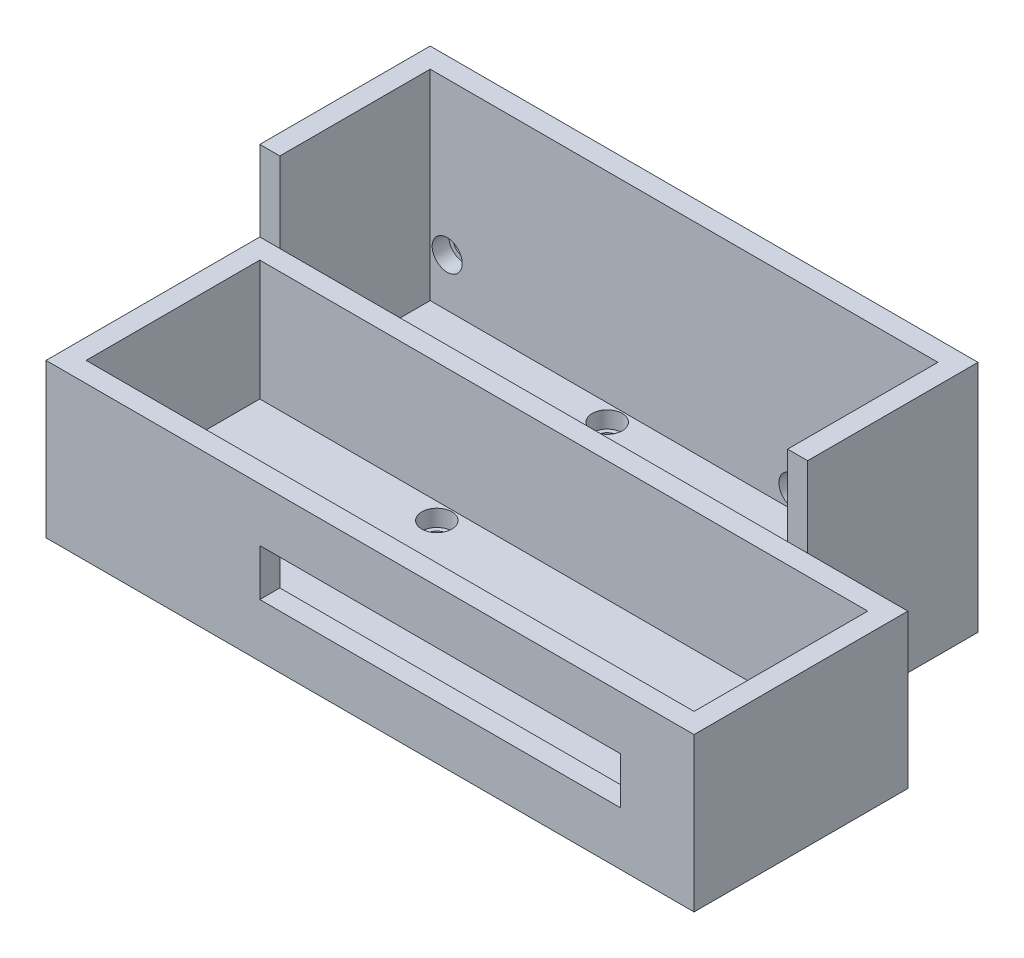
from build123d import *

# Parameters (mm, degrees)
SKETCH1_W           = 91
SKETCH1_H           = 26
BOSS_EXTRUDE1_DEPTH = 5
SKETCH2_R           = 2.25
CUT_EXTRUDE1_DEPTH  = 2.5
SKETCH4_R           = 1.6
CUT_EXTRUDE3_DEPTH  = 3.5
SKETCH5_W           = 97
SKETCH5_H           = 32
SKETCH5_W_2         = 91
SKETCH5_H_2         = 26
BOSS_EXTRUDE2_DEPTH = 23
CUT_EXTRUDE4_REACH  = 34
SKETCH6_W           = 54
SKETCH6_H           = 7
SKETCH9_W           = 76
SKETCH9_H           = 5
BOSS_EXTRUDE3_DEPTH = 22.5
SKETCH10_R          = 2.25
CUT_EXTRUDE5_DEPTH  = 2.5
SKETCH11_R          = 1.6
CUT_EXTRUDE6_DEPTH  = 3.5
BOSS_EXTRUDE4_DEPTH = 35
CUT_EXTRUDE7_REACH  = 84
SKETCH13_R          = 1.6
CUT_EXTRUDE8_REACH  = 59.5
SKETCH14_R          = 1.6
SKETCH16_R          = 2.25
CUT_EXTRUDE10_DEPTH = 2.5
SKETCH17_R          = 2.5
SKETCH17_R_2        = 1.6
BOSS_EXTRUDE5_DEPTH = 1.3
SKETCH18_R          = 2.25
CUT_EXTRUDE11_DEPTH = 1.5


with BuildPart() as part:
    # Sketch1 → Boss-Extrude1 (new body)
    with BuildSketch(Plane(origin=(0, 0, 0), x_dir=(1, 0, 0), z_dir=(0, 1, 0))):
        with Locations((45.5, 13)):
            Rectangle(SKETCH1_W, SKETCH1_H)
    extrude(amount=BOSS_EXTRUDE1_DEPTH)

    # Sketch2 → Cut-Extrude1 (cut)
    with BuildSketch(Plane(origin=(0, 5, 0), x_dir=(1, 0, 0), z_dir=(0, 1, 0))):
        with Locations((2.5, 2.5)):
            Circle(SKETCH2_R)
        with Locations((88.5, 2.5)):
            Circle(SKETCH2_R)
        with Locations((29, 23.5)):
            Circle(SKETCH2_R)
    extrude(amount=-CUT_EXTRUDE1_DEPTH, mode=Mode.SUBTRACT)

    # Sketch4 → Cut-Extrude3 (cut, through all)
    with BuildSketch(Plane(origin=(0, 2.5, 0), x_dir=(1, 0, 0), z_dir=(0, 1, 0))):
        with Locations((2.5, 2.5)):
            Circle(SKETCH4_R)
        with Locations((29, 23.5)):
            Circle(SKETCH4_R)
        with Locations((88.5, 2.5)):
            Circle(SKETCH4_R)
    extrude(amount=-CUT_EXTRUDE3_DEPTH, mode=Mode.SUBTRACT)

    # Sketch5 → Boss-Extrude2 (add)
    with BuildSketch(Plane.XZ):
        with Locations((45.5, -13)):
            Rectangle(SKETCH5_W, SKETCH5_H)
        with Locations((45.5, -13)):
            Rectangle(SKETCH5_W_2, SKETCH5_H_2, mode=Mode.SUBTRACT)
    extrude(amount=-BOSS_EXTRUDE2_DEPTH)

    # Sketch6 → Cut-Extrude4 (cut, up to next)
    with BuildSketch(Plane.XY.offset(3), mode=Mode.PRIVATE) as cut_extrude4_sk1:
        with Locations((56, 11.5)):
            Rectangle(SKETCH6_W, SKETCH6_H)
    cut_extrude4_tool1 = extrude(cut_extrude4_sk1.sketch, amount=-CUT_EXTRUDE4_REACH, mode=Mode.PRIVATE) & part.part
    add(cut_extrude4_tool1.solids().sort_by_distance((56, 11.5, 3))[0], mode=Mode.SUBTRACT)

    # Sketch9 → Boss-Extrude3 (add)
    with BuildSketch(Plane(origin=(0, 0, -29), x_dir=(-1, 0, 0), z_dir=(0, 0, -1))):
        with Locations((-38, 2.5)):
            Rectangle(SKETCH9_W, SKETCH9_H)
    extrude(amount=BOSS_EXTRUDE3_DEPTH)

    # Sketch10 → Cut-Extrude5 (cut)
    with BuildSketch(Plane(origin=(0, 5, 0), x_dir=(1, 0, 0), z_dir=(0, 1, 0))):
        with Locations((29, 49)):
            Circle(SKETCH10_R)
    extrude(amount=-CUT_EXTRUDE5_DEPTH, mode=Mode.SUBTRACT)

    # Sketch11 → Cut-Extrude6 (cut, through all)
    with BuildSketch(Plane(origin=(0, 2.5, 0), x_dir=(1, 0, 0), z_dir=(0, 1, 0))):
        with Locations((29, 49)):
            Circle(SKETCH11_R)
    extrude(amount=-CUT_EXTRUDE6_DEPTH, mode=Mode.SUBTRACT)

    # Sketch12 → Boss-Extrude4 (add)
    with BuildSketch(Plane.XZ):
        Polygon((0, -29), (-3, -29), (-3, -54.5), (0, -54.5), (79, -54.5), (79, -51.5), (79, -29), (76, -29), (76, -51.5), (0, -51.5), align=None)
    extrude(amount=-BOSS_EXTRUDE4_DEPTH)

    # Sketch13 → Cut-Extrude7 (cut, up to next)
    with BuildSketch(Plane(origin=(79, 0, 0), x_dir=(0, 0, -1), z_dir=(1, 0, 0)), mode=Mode.PRIVATE) as cut_extrude7_sk1:
        with Locations((31.5, 10)):
            Circle(SKETCH13_R)
    cut_extrude7_tool1 = extrude(cut_extrude7_sk1.sketch, amount=-CUT_EXTRUDE7_REACH, mode=Mode.PRIVATE) & part.part
    add(cut_extrude7_tool1.solids().sort_by_distance((79, 10, -31.5))[0], mode=Mode.SUBTRACT)

    # Sketch14 → Cut-Extrude8 (cut, up to next)
    with BuildSketch(Plane(origin=(0, 0, -54.5), x_dir=(-1, 0, 0), z_dir=(0, 0, -1)), mode=Mode.PRIVATE) as cut_extrude8_sk1:
        with Locations((-54.45, 7.5)):
            Circle(SKETCH14_R)
    cut_extrude8_tool1 = extrude(cut_extrude8_sk1.sketch, amount=-CUT_EXTRUDE8_REACH, mode=Mode.PRIVATE) & part.part
    add(cut_extrude8_tool1.solids().sort_by_distance((54.45, 7.5, -54.5))[0], mode=Mode.SUBTRACT)
    # Sketch14 → Cut-Extrude8 (cut, up to next)
    with BuildSketch(Plane(origin=(0, 0, -54.5), x_dir=(-1, 0, 0), z_dir=(0, 0, -1)), mode=Mode.PRIVATE) as cut_extrude8_sk2:
        with Locations((-2.55, 12.2)):
            Circle(SKETCH14_R)
    cut_extrude8_tool2 = extrude(cut_extrude8_sk2.sketch, amount=-CUT_EXTRUDE8_REACH, mode=Mode.PRIVATE) & part.part
    add(cut_extrude8_tool2.solids().sort_by_distance((2.55, 12.2, -54.5))[0], mode=Mode.SUBTRACT)

    # Sketch16 → Cut-Extrude10 (cut)
    with BuildSketch(Plane.XY.offset(-51.5)):
        with Locations((2.55, 12.2)):
            Circle(SKETCH16_R)
        with Locations((54.45, 7.5)):
            Circle(SKETCH16_R)
    extrude(amount=-CUT_EXTRUDE10_DEPTH, mode=Mode.SUBTRACT)

    # Sketch17 → Boss-Extrude5 (add)
    with BuildSketch(Plane(origin=(0, 0, -54.5), x_dir=(-1, 0, 0), z_dir=(0, 0, -1))):
        with Locations((-54.45, 7.5)):
            Circle(SKETCH17_R)
        with Locations((-54.45, 7.5)):
            Circle(SKETCH17_R_2, mode=Mode.SUBTRACT)
        with Locations((-2.55, 12.2)):
            Circle(SKETCH17_R)
        with Locations((-2.55, 12.2)):
            Circle(SKETCH17_R_2, mode=Mode.SUBTRACT)
    extrude(amount=BOSS_EXTRUDE5_DEPTH)

    # Sketch18 → Cut-Extrude11 (cut)
    with BuildSketch(Plane.ZY.offset(-76)):
        with Locations((-31.5, 10)):
            Circle(SKETCH18_R)
    extrude(amount=-CUT_EXTRUDE11_DEPTH, mode=Mode.SUBTRACT)


solid = part.part
